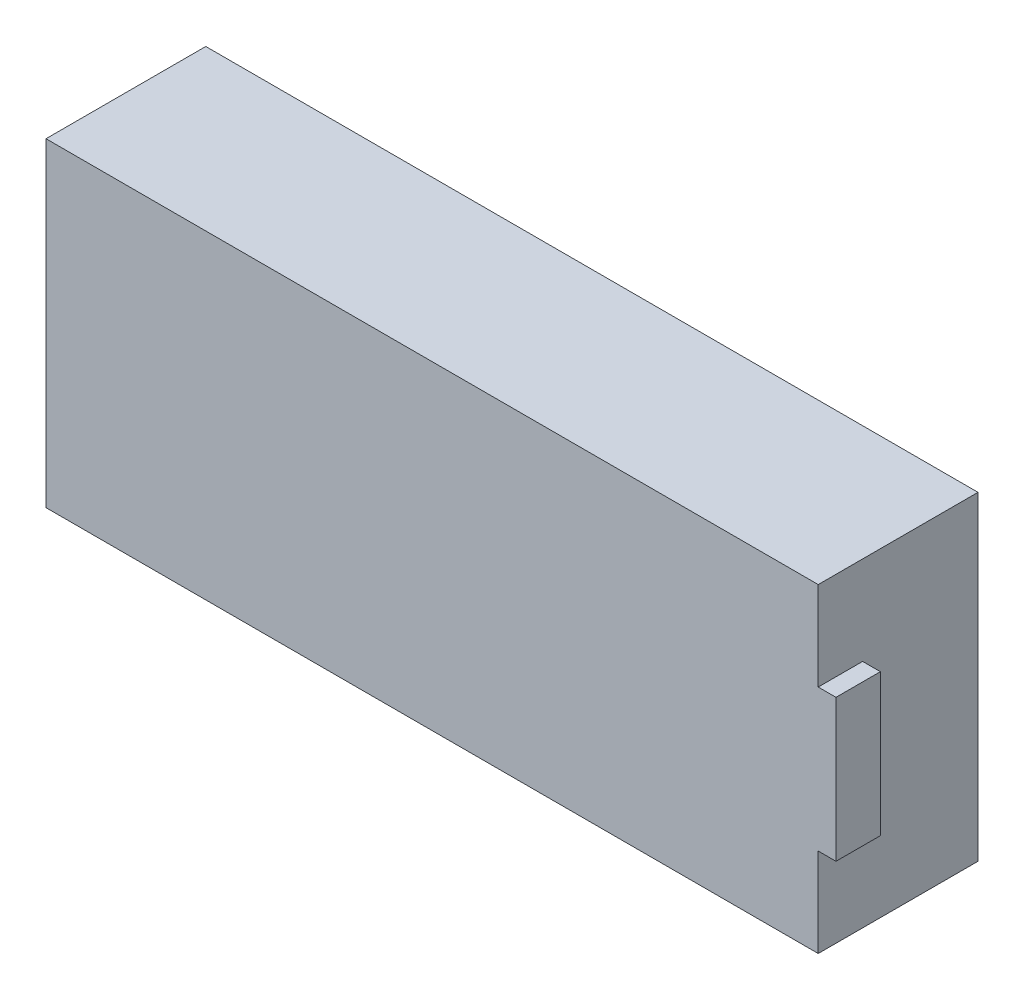
from build123d import *

# Parameters (mm, degrees)
SKETCH1_W           = 43.5
SKETCH1_H           = 18
BOSS_EXTRUDE1_DEPTH = 9
SKETCH2_W           = 2.5
SKETCH2_H           = 8
BOSS_EXTRUDE2_DEPTH = 1


with BuildPart() as part:
    # Sketch1 → Boss-Extrude1 (new body)
    with BuildSketch(Plane.XY):
        with Locations((21.75, 9)):
            Rectangle(SKETCH1_W, SKETCH1_H)
    extrude(amount=BOSS_EXTRUDE1_DEPTH)

    # Sketch2 → Boss-Extrude2 (add)
    with BuildSketch(Plane(origin=(43.5, 0, 0), x_dir=(0, 0, -1), z_dir=(1, 0, 0))):
        with Locations((-7.75, 9)):
            Rectangle(SKETCH2_W, SKETCH2_H)
    extrude(amount=BOSS_EXTRUDE2_DEPTH)


solid = part.part
